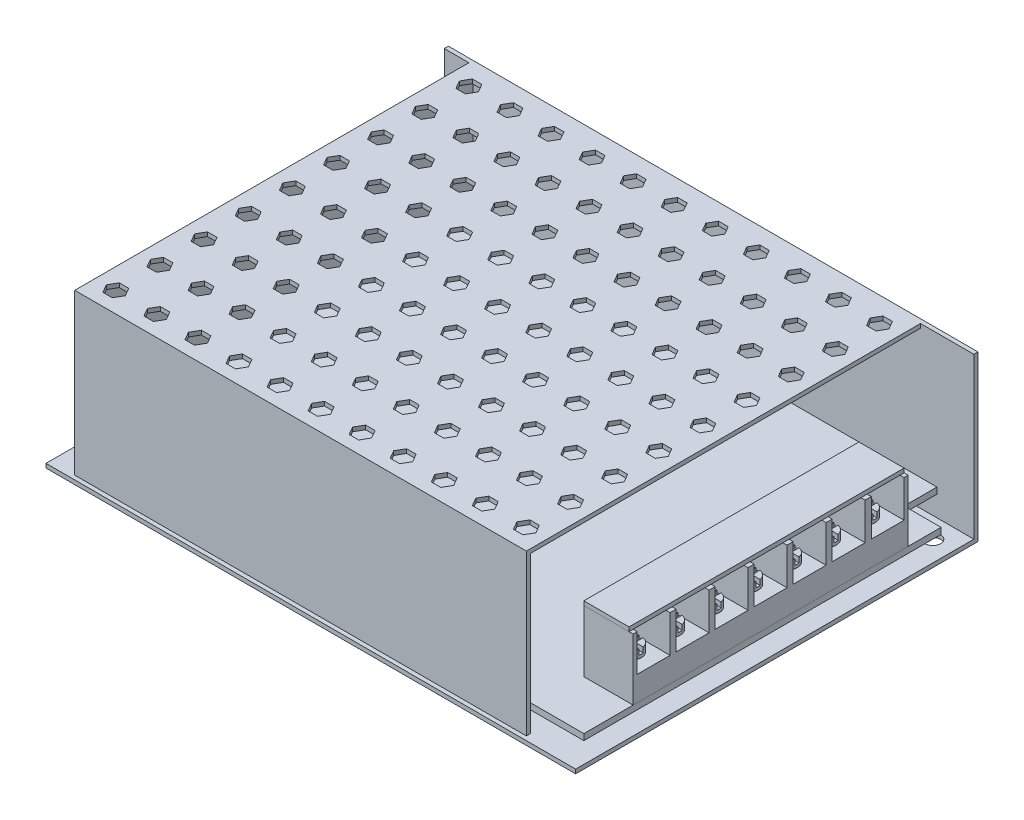
from build123d import *

# Parameters (mm, degrees)
SKETCH1_W           = 129
SKETCH1_H           = 98
BOSS_EXTRUDE1_DEPTH = 1
BOSS_EXTRUDE2_DEPTH = 39
SKETCH4_W           = 110
SKETCH4_H           = 1
BOSS_EXTRUDE3_DEPTH = 95
CUT_EXTRUDE1_DEPTH  = 1
BOSS_EXTRUDE4_DEPTH = 1.5
SKETCH8_W           = 12
SKETCH8_H           = 67
BOSS_EXTRUDE5_DEPTH = 15
SKETCH9_W           = 11
SKETCH9_H           = 8
CUT_EXTRUDE2_DEPTH  = 9
SKETCH10_R          = 2.5
BOSS_EXTRUDE6_DEPTH = 2
CUT_EXTRUDE3_DEPTH  = 1.25
LPATTERN4_COUNT     = 7
LPATTERN4_PITCH     = 9.493925628
LPATTERN4_2_COUNT   = 7
LPATTERN4_2_PITCH   = 9.493925628
SKETCH12_W          = 11
SKETCH12_H          = 67
BOSS_EXTRUDE7_DEPTH = 1
SKETCH13_R          = 1.9
CUT_EXTRUDE4_DEPTH  = 90.901334807


with BuildPart() as part:
    # Sketch1 → Boss-Extrude1 (new body)
    with BuildSketch(Plane(origin=(0, 0, 0), x_dir=(1, 0, 0), z_dir=(0, 1, 0))):
        Rectangle(SKETCH1_W, SKETCH1_H)
    extrude(amount=BOSS_EXTRUDE1_DEPTH)

    # Sketch2 → Boss-Extrude2 (add)
    with BuildSketch(Plane(origin=(0, 1, 0), x_dir=(1, 0, 0), z_dir=(0, 1, 0))):
        Polygon((-64.5, 49), (64.5, 49), (64.5, 48), (-57.5, 48), (-57.5, -47), (51.5, -47), (51.5, -48), (-58.5, -48), (-58.5, -47), (-58.5, 48), (-64.5, 48), align=None)
    extrude(amount=BOSS_EXTRUDE2_DEPTH)

    # Sketch4 → Boss-Extrude3 (add)
    with BuildSketch(Plane(origin=(0, 0, 47), x_dir=(-1, 0, 0), z_dir=(0, 0, -1))):
        with Locations((3.5, 39.5)):
            Rectangle(SKETCH4_W, SKETCH4_H)
    extrude(amount=BOSS_EXTRUDE3_DEPTH)

    # Sketch5 → Cut-Extrude1 (cut)
    with BuildSketch(Plane(origin=(0, 40, 0), x_dir=(1, 0, 0), z_dir=(0, 1, 0))):
        Polygon((-51.190598923, 43), (-52.345299462, 45), (-54.654700538, 45), (-55.809401077, 43), (-54.654700538, 41), (-52.345299462, 41), align=None)
        Polygon((-41.190598923, 43), (-42.345299462, 45), (-44.654700538, 45), (-45.809401077, 43), (-44.654700538, 41), (-42.345299462, 41), align=None)
        Polygon((-31.190598923, 43), (-32.345299462, 45), (-34.654700538, 45), (-35.809401077, 43), (-34.654700538, 41), (-32.345299462, 41), align=None)
        Polygon((-21.190598923, 43), (-22.345299462, 45), (-24.654700538, 45), (-25.809401077, 43), (-24.654700538, 41), (-22.345299462, 41), align=None)
        Polygon((-11.190598923, 43), (-12.345299462, 45), (-14.654700538, 45), (-15.809401077, 43), (-14.654700538, 41), (-12.345299462, 41), align=None)
        Polygon((-1.190598923, 43), (-2.345299462, 45), (-4.654700538, 45), (-5.809401077, 43), (-4.654700538, 41), (-2.345299462, 41), align=None)
        Polygon((8.809401077, 43), (7.654700538, 45), (5.345299462, 45), (4.190598923, 43), (5.345299462, 41), (7.654700538, 41), align=None)
        Polygon((18.809401077, 43), (17.654700538, 45), (15.345299462, 45), (14.190598923, 43), (15.345299462, 41), (17.654700538, 41), align=None)
        Polygon((28.809401077, 43), (27.654700538, 45), (25.345299462, 45), (24.190598923, 43), (25.345299462, 41), (27.654700538, 41), align=None)
        Polygon((38.809401077, 43), (37.654700538, 45), (35.345299462, 45), (34.190598923, 43), (35.345299462, 41), (37.654700538, 41), align=None)
        Polygon((48.809401077, 43), (47.654700538, 45), (45.345299462, 45), (44.190598923, 43), (45.345299462, 41), (47.654700538, 41), align=None)
        Polygon((-41.190598923, 32.25), (-42.345299462, 34.25), (-44.654700538, 34.25), (-45.809401077, 32.25), (-44.654700538, 30.25), (-42.345299462, 30.25), align=None)
        Polygon((-31.190598923, 32.25), (-32.345299462, 34.25), (-34.654700538, 34.25), (-35.809401077, 32.25), (-34.654700538, 30.25), (-32.345299462, 30.25), align=None)
        Polygon((-21.190598923, 32.25), (-22.345299462, 34.25), (-24.654700538, 34.25), (-25.809401077, 32.25), (-24.654700538, 30.25), (-22.345299462, 30.25), align=None)
        Polygon((-11.190598923, 32.25), (-12.345299462, 34.25), (-14.654700538, 34.25), (-15.809401077, 32.25), (-14.654700538, 30.25), (-12.345299462, 30.25), align=None)
        Polygon((-1.190598923, 32.25), (-2.345299462, 34.25), (-4.654700538, 34.25), (-5.809401077, 32.25), (-4.654700538, 30.25), (-2.345299462, 30.25), align=None)
        Polygon((8.809401077, 32.25), (7.654700538, 34.25), (5.345299462, 34.25), (4.190598923, 32.25), (5.345299462, 30.25), (7.654700538, 30.25), align=None)
        Polygon((18.809401077, 32.25), (17.654700538, 34.25), (15.345299462, 34.25), (14.190598923, 32.25), (15.345299462, 30.25), (17.654700538, 30.25), align=None)
        Polygon((28.809401077, 32.25), (27.654700538, 34.25), (25.345299462, 34.25), (24.190598923, 32.25), (25.345299462, 30.25), (27.654700538, 30.25), align=None)
        Polygon((38.809401077, 32.25), (37.654700538, 34.25), (35.345299462, 34.25), (34.190598923, 32.25), (35.345299462, 30.25), (37.654700538, 30.25), align=None)
        Polygon((48.809401077, 32.25), (47.654700538, 34.25), (45.345299462, 34.25), (44.190598923, 32.25), (45.345299462, 30.25), (47.654700538, 30.25), align=None)
        Polygon((-41.190598923, 21.5), (-42.345299462, 23.5), (-44.654700538, 23.5), (-45.809401077, 21.5), (-44.654700538, 19.5), (-42.345299462, 19.5), align=None)
        Polygon((-31.190598923, 21.5), (-32.345299462, 23.5), (-34.654700538, 23.5), (-35.809401077, 21.5), (-34.654700538, 19.5), (-32.345299462, 19.5), align=None)
        Polygon((-21.190598923, 21.5), (-22.345299462, 23.5), (-24.654700538, 23.5), (-25.809401077, 21.5), (-24.654700538, 19.5), (-22.345299462, 19.5), align=None)
        Polygon((-11.190598923, 21.5), (-12.345299462, 23.5), (-14.654700538, 23.5), (-15.809401077, 21.5), (-14.654700538, 19.5), (-12.345299462, 19.5), align=None)
        Polygon((-1.190598923, 21.5), (-2.345299462, 23.5), (-4.654700538, 23.5), (-5.809401077, 21.5), (-4.654700538, 19.5), (-2.345299462, 19.5), align=None)
        Polygon((8.809401077, 21.5), (7.654700538, 23.5), (5.345299462, 23.5), (4.190598923, 21.5), (5.345299462, 19.5), (7.654700538, 19.5), align=None)
        Polygon((18.809401077, 21.5), (17.654700538, 23.5), (15.345299462, 23.5), (14.190598923, 21.5), (15.345299462, 19.5), (17.654700538, 19.5), align=None)
        Polygon((28.809401077, 21.5), (27.654700538, 23.5), (25.345299462, 23.5), (24.190598923, 21.5), (25.345299462, 19.5), (27.654700538, 19.5), align=None)
        Polygon((38.809401077, 21.5), (37.654700538, 23.5), (35.345299462, 23.5), (34.190598923, 21.5), (35.345299462, 19.5), (37.654700538, 19.5), align=None)
        Polygon((48.809401077, 21.5), (47.654700538, 23.5), (45.345299462, 23.5), (44.190598923, 21.5), (45.345299462, 19.5), (47.654700538, 19.5), align=None)
        Polygon((-41.190598923, 10.75), (-42.345299462, 12.75), (-44.654700538, 12.75), (-45.809401077, 10.75), (-44.654700538, 8.75), (-42.345299462, 8.75), align=None)
        Polygon((-31.190598923, 10.75), (-32.345299462, 12.75), (-34.654700538, 12.75), (-35.809401077, 10.75), (-34.654700538, 8.75), (-32.345299462, 8.75), align=None)
        Polygon((-21.190598923, 10.75), (-22.345299462, 12.75), (-24.654700538, 12.75), (-25.809401077, 10.75), (-24.654700538, 8.75), (-22.345299462, 8.75), align=None)
        Polygon((-11.190598923, 10.75), (-12.345299462, 12.75), (-14.654700538, 12.75), (-15.809401077, 10.75), (-14.654700538, 8.75), (-12.345299462, 8.75), align=None)
        Polygon((-1.190598923, 10.75), (-2.345299462, 12.75), (-4.654700538, 12.75), (-5.809401077, 10.75), (-4.654700538, 8.75), (-2.345299462, 8.75), align=None)
        Polygon((8.809401077, 10.75), (7.654700538, 12.75), (5.345299462, 12.75), (4.190598923, 10.75), (5.345299462, 8.75), (7.654700538, 8.75), align=None)
        Polygon((18.809401077, 10.75), (17.654700538, 12.75), (15.345299462, 12.75), (14.190598923, 10.75), (15.345299462, 8.75), (17.654700538, 8.75), align=None)
        Polygon((28.809401077, 10.75), (27.654700538, 12.75), (25.345299462, 12.75), (24.190598923, 10.75), (25.345299462, 8.75), (27.654700538, 8.75), align=None)
        Polygon((38.809401077, 10.75), (37.654700538, 12.75), (35.345299462, 12.75), (34.190598923, 10.75), (35.345299462, 8.75), (37.654700538, 8.75), align=None)
        Polygon((48.809401077, 10.75), (47.654700538, 12.75), (45.345299462, 12.75), (44.190598923, 10.75), (45.345299462, 8.75), (47.654700538, 8.75), align=None)
        Polygon((-41.190598923, 0), (-42.345299462, 2), (-44.654700538, 2), (-45.809401077, 0), (-44.654700538, -2), (-42.345299462, -2), align=None)
        Polygon((-31.190598923, 0), (-32.345299462, 2), (-34.654700538, 2), (-35.809401077, 0), (-34.654700538, -2), (-32.345299462, -2), align=None)
        Polygon((-21.190598923, 0), (-22.345299462, 2), (-24.654700538, 2), (-25.809401077, 0), (-24.654700538, -2), (-22.345299462, -2), align=None)
        Polygon((-11.190598923, 0), (-12.345299462, 2), (-14.654700538, 2), (-15.809401077, 0), (-14.654700538, -2), (-12.345299462, -2), align=None)
        Polygon((-1.190598923, 0), (-2.345299462, 2), (-4.654700538, 2), (-5.809401077, 0), (-4.654700538, -2), (-2.345299462, -2), align=None)
        Polygon((8.809401077, 0), (7.654700538, 2), (5.345299462, 2), (4.190598923, 0), (5.345299462, -2), (7.654700538, -2), align=None)
        Polygon((18.809401077, 0), (17.654700538, 2), (15.345299462, 2), (14.190598923, 0), (15.345299462, -2), (17.654700538, -2), align=None)
        Polygon((28.809401077, 0), (27.654700538, 2), (25.345299462, 2), (24.190598923, 0), (25.345299462, -2), (27.654700538, -2), align=None)
        Polygon((38.809401077, 0), (37.654700538, 2), (35.345299462, 2), (34.190598923, 0), (35.345299462, -2), (37.654700538, -2), align=None)
        Polygon((48.809401077, 0), (47.654700538, 2), (45.345299462, 2), (44.190598923, 0), (45.345299462, -2), (47.654700538, -2), align=None)
        Polygon((-41.190598923, -10.75), (-42.345299462, -8.75), (-44.654700538, -8.75), (-45.809401077, -10.75), (-44.654700538, -12.75), (-42.345299462, -12.75), align=None)
        Polygon((-31.190598923, -10.75), (-32.345299462, -8.75), (-34.654700538, -8.75), (-35.809401077, -10.75), (-34.654700538, -12.75), (-32.345299462, -12.75), align=None)
        Polygon((-21.190598923, -10.75), (-22.345299462, -8.75), (-24.654700538, -8.75), (-25.809401077, -10.75), (-24.654700538, -12.75), (-22.345299462, -12.75), align=None)
        Polygon((-11.190598923, -10.75), (-12.345299462, -8.75), (-14.654700538, -8.75), (-15.809401077, -10.75), (-14.654700538, -12.75), (-12.345299462, -12.75), align=None)
        Polygon((-1.190598923, -10.75), (-2.345299462, -8.75), (-4.654700538, -8.75), (-5.809401077, -10.75), (-4.654700538, -12.75), (-2.345299462, -12.75), align=None)
        Polygon((8.809401077, -10.75), (7.654700538, -8.75), (5.345299462, -8.75), (4.190598923, -10.75), (5.345299462, -12.75), (7.654700538, -12.75), align=None)
        Polygon((18.809401077, -10.75), (17.654700538, -8.75), (15.345299462, -8.75), (14.190598923, -10.75), (15.345299462, -12.75), (17.654700538, -12.75), align=None)
        Polygon((28.809401077, -10.75), (27.654700538, -8.75), (25.345299462, -8.75), (24.190598923, -10.75), (25.345299462, -12.75), (27.654700538, -12.75), align=None)
        Polygon((38.809401077, -10.75), (37.654700538, -8.75), (35.345299462, -8.75), (34.190598923, -10.75), (35.345299462, -12.75), (37.654700538, -12.75), align=None)
        Polygon((48.809401077, -10.75), (47.654700538, -8.75), (45.345299462, -8.75), (44.190598923, -10.75), (45.345299462, -12.75), (47.654700538, -12.75), align=None)
        Polygon((-41.190598923, -21.5), (-42.345299462, -19.5), (-44.654700538, -19.5), (-45.809401077, -21.5), (-44.654700538, -23.5), (-42.345299462, -23.5), align=None)
        Polygon((-31.190598923, -21.5), (-32.345299462, -19.5), (-34.654700538, -19.5), (-35.809401077, -21.5), (-34.654700538, -23.5), (-32.345299462, -23.5), align=None)
        Polygon((-21.190598923, -21.5), (-22.345299462, -19.5), (-24.654700538, -19.5), (-25.809401077, -21.5), (-24.654700538, -23.5), (-22.345299462, -23.5), align=None)
        Polygon((-11.190598923, -21.5), (-12.345299462, -19.5), (-14.654700538, -19.5), (-15.809401077, -21.5), (-14.654700538, -23.5), (-12.345299462, -23.5), align=None)
        Polygon((-1.190598923, -21.5), (-2.345299462, -19.5), (-4.654700538, -19.5), (-5.809401077, -21.5), (-4.654700538, -23.5), (-2.345299462, -23.5), align=None)
        Polygon((8.809401077, -21.5), (7.654700538, -19.5), (5.345299462, -19.5), (4.190598923, -21.5), (5.345299462, -23.5), (7.654700538, -23.5), align=None)
        Polygon((18.809401077, -21.5), (17.654700538, -19.5), (15.345299462, -19.5), (14.190598923, -21.5), (15.345299462, -23.5), (17.654700538, -23.5), align=None)
        Polygon((28.809401077, -21.5), (27.654700538, -19.5), (25.345299462, -19.5), (24.190598923, -21.5), (25.345299462, -23.5), (27.654700538, -23.5), align=None)
        Polygon((38.809401077, -21.5), (37.654700538, -19.5), (35.345299462, -19.5), (34.190598923, -21.5), (35.345299462, -23.5), (37.654700538, -23.5), align=None)
        Polygon((48.809401077, -21.5), (47.654700538, -19.5), (45.345299462, -19.5), (44.190598923, -21.5), (45.345299462, -23.5), (47.654700538, -23.5), align=None)
        Polygon((-41.190598923, -32.25), (-42.345299462, -30.25), (-44.654700538, -30.25), (-45.809401077, -32.25), (-44.654700538, -34.25), (-42.345299462, -34.25), align=None)
        Polygon((-31.190598923, -32.25), (-32.345299462, -30.25), (-34.654700538, -30.25), (-35.809401077, -32.25), (-34.654700538, -34.25), (-32.345299462, -34.25), align=None)
        Polygon((-21.190598923, -32.25), (-22.345299462, -30.25), (-24.654700538, -30.25), (-25.809401077, -32.25), (-24.654700538, -34.25), (-22.345299462, -34.25), align=None)
        Polygon((-11.190598923, -32.25), (-12.345299462, -30.25), (-14.654700538, -30.25), (-15.809401077, -32.25), (-14.654700538, -34.25), (-12.345299462, -34.25), align=None)
        Polygon((-1.190598923, -32.25), (-2.345299462, -30.25), (-4.654700538, -30.25), (-5.809401077, -32.25), (-4.654700538, -34.25), (-2.345299462, -34.25), align=None)
        Polygon((8.809401077, -32.25), (7.654700538, -30.25), (5.345299462, -30.25), (4.190598923, -32.25), (5.345299462, -34.25), (7.654700538, -34.25), align=None)
        Polygon((18.809401077, -32.25), (17.654700538, -30.25), (15.345299462, -30.25), (14.190598923, -32.25), (15.345299462, -34.25), (17.654700538, -34.25), align=None)
        Polygon((28.809401077, -32.25), (27.654700538, -30.25), (25.345299462, -30.25), (24.190598923, -32.25), (25.345299462, -34.25), (27.654700538, -34.25), align=None)
        Polygon((38.809401077, -32.25), (37.654700538, -30.25), (35.345299462, -30.25), (34.190598923, -32.25), (35.345299462, -34.25), (37.654700538, -34.25), align=None)
        Polygon((48.809401077, -32.25), (47.654700538, -30.25), (45.345299462, -30.25), (44.190598923, -32.25), (45.345299462, -34.25), (47.654700538, -34.25), align=None)
        Polygon((-41.190598923, -43), (-42.345299462, -41), (-44.654700538, -41), (-45.809401077, -43), (-44.654700538, -45), (-42.345299462, -45), align=None)
        Polygon((-31.190598923, -43), (-32.345299462, -41), (-34.654700538, -41), (-35.809401077, -43), (-34.654700538, -45), (-32.345299462, -45), align=None)
        Polygon((-21.190598923, -43), (-22.345299462, -41), (-24.654700538, -41), (-25.809401077, -43), (-24.654700538, -45), (-22.345299462, -45), align=None)
        Polygon((-11.190598923, -43), (-12.345299462, -41), (-14.654700538, -41), (-15.809401077, -43), (-14.654700538, -45), (-12.345299462, -45), align=None)
        Polygon((-1.190598923, -43), (-2.345299462, -41), (-4.654700538, -41), (-5.809401077, -43), (-4.654700538, -45), (-2.345299462, -45), align=None)
        Polygon((8.809401077, -43), (7.654700538, -41), (5.345299462, -41), (4.190598923, -43), (5.345299462, -45), (7.654700538, -45), align=None)
        Polygon((18.809401077, -43), (17.654700538, -41), (15.345299462, -41), (14.190598923, -43), (15.345299462, -45), (17.654700538, -45), align=None)
        Polygon((28.809401077, -43), (27.654700538, -41), (25.345299462, -41), (24.190598923, -43), (25.345299462, -45), (27.654700538, -45), align=None)
        Polygon((38.809401077, -43), (37.654700538, -41), (35.345299462, -41), (34.190598923, -43), (35.345299462, -45), (37.654700538, -45), align=None)
        Polygon((48.809401077, -43), (47.654700538, -41), (45.345299462, -41), (44.190598923, -43), (45.345299462, -45), (47.654700538, -45), align=None)
        Polygon((-51.190598923, 32.25), (-52.345299462, 34.25), (-54.654700538, 34.25), (-55.809401077, 32.25), (-54.654700538, 30.25), (-52.345299462, 30.25), align=None)
        Polygon((-51.190598923, 21.5), (-52.345299462, 23.5), (-54.654700538, 23.5), (-55.809401077, 21.5), (-54.654700538, 19.5), (-52.345299462, 19.5), align=None)
        Polygon((-51.190598923, 10.75), (-52.345299462, 12.75), (-54.654700538, 12.75), (-55.809401077, 10.75), (-54.654700538, 8.75), (-52.345299462, 8.75), align=None)
        Polygon((-51.190598923, 0), (-52.345299462, 2), (-54.654700538, 2), (-55.809401077, 0), (-54.654700538, -2), (-52.345299462, -2), align=None)
        Polygon((-51.190598923, -10.75), (-52.345299462, -8.75), (-54.654700538, -8.75), (-55.809401077, -10.75), (-54.654700538, -12.75), (-52.345299462, -12.75), align=None)
        Polygon((-51.190598923, -21.5), (-52.345299462, -19.5), (-54.654700538, -19.5), (-55.809401077, -21.5), (-54.654700538, -23.5), (-52.345299462, -23.5), align=None)
        Polygon((-51.190598923, -32.25), (-52.345299462, -30.25), (-54.654700538, -30.25), (-55.809401077, -32.25), (-54.654700538, -34.25), (-52.345299462, -34.25), align=None)
        Polygon((-51.190598923, -43), (-52.345299462, -41), (-54.654700538, -41), (-55.809401077, -43), (-54.654700538, -45), (-52.345299462, -45), align=None)
    extrude(amount=-CUT_EXTRUDE1_DEPTH, mode=Mode.SUBTRACT)

    # Sketch13 → Cut-Extrude4 (cut, through all)
    with BuildSketch(Plane(origin=(0, 1, 0), x_dir=(1, 0, 0), z_dir=(0, 1, 0))):
        with Locations(Location((59.5, 43, 0), (0, 0, 270))):
            Circle(SKETCH13_R)
    extrude(amount=-CUT_EXTRUDE4_DEPTH, mode=Mode.SUBTRACT)


with BuildPart() as body_2:
    # Sketch7 → Boss-Extrude4 (new body)
    with BuildSketch(Plane(origin=(0, 6, 0), x_dir=(1, 0, 0), z_dir=(0, 1, 0))):
        Polygon((55.5, 48), (55.5, 40), (64.5, 40), (64.5, -47), (-57.5, -47), (-57.5, 48), align=None)
    extrude(amount=BOSS_EXTRUDE4_DEPTH)


with BuildPart() as body_3:
    # Sketch8 → Boss-Extrude5 (new body)
    with BuildSketch(Plane(origin=(0, 7.5, 0), x_dir=(1, 0, 0), z_dir=(0, 1, 0))):
        with Locations((58.5, -1.5)):
            Rectangle(SKETCH8_W, SKETCH8_H)
    extrude(amount=BOSS_EXTRUDE5_DEPTH)

    # Sketch9 → Cut-Extrude2 (cut)
    with BuildSketch(Plane(origin=(0, 22.5, 0), x_dir=(1, 0, 0), z_dir=(0, 1, 0))):
        with Locations((59, -30)):
            Rectangle(SKETCH9_W, SKETCH9_H)
        with Locations((59, -20.5)):
            Rectangle(SKETCH9_W, SKETCH9_H)
        with Locations((59, -11)):
            Rectangle(SKETCH9_W, SKETCH9_H)
        with Locations((59, -1.5)):
            Rectangle(SKETCH9_W, SKETCH9_H)
        with Locations((59, 8)):
            Rectangle(SKETCH9_W, SKETCH9_H)
        with Locations((59, 17.5)):
            Rectangle(SKETCH9_W, SKETCH9_H)
        with Locations((59, 27)):
            Rectangle(SKETCH9_W, SKETCH9_H)
    extrude(amount=-CUT_EXTRUDE2_DEPTH, mode=Mode.SUBTRACT)


with BuildPart() as body_4:
    # Sketch10 → Boss-Extrude6 (new body)
    with BuildSketch(Plane(origin=(0, 13.5, 0), x_dir=(1, 0, 0), z_dir=(0, 1, 0))):
        with Locations(Location((59, -30, 0), (0, 0, 270))):
            Circle(SKETCH10_R)
    boss_extrude6 = extrude(amount=BOSS_EXTRUDE6_DEPTH)

    # Sketch11 → Cut-Extrude3 (cut)
    with BuildSketch(Plane(origin=(0, 15.5, 0), x_dir=(1, 0, 0), z_dir=(0, 1, 0))):
        Polygon((62.497624325, -29.5), (62.497624325, -30.5), (59.5, -30.5), (59.5, -33.166665013), (58.5, -33.166665013), (58.5, -30.5), (55.577516505, -30.5), (55.577516505, -29.5), (58.5, -29.5), (58.5, -26.693775045), (59.5, -26.693775045), (59.5, -29.5), align=None)
    cut_extrude3 = extrude(amount=-CUT_EXTRUDE3_DEPTH, mode=Mode.SUBTRACT)


with BuildPart() as lpattern4_1:
    # LPattern4: pattern copy
    add(boss_extrude6.moved(Location(Vector(0, 0, -1) * (1 * LPATTERN4_PITCH))))


with BuildPart() as lpattern4_2:
    # LPattern4: pattern copy
    add(boss_extrude6.moved(Location(Vector(0, 0, -1) * (2 * LPATTERN4_PITCH))))


with BuildPart() as lpattern4_3:
    # LPattern4: pattern copy
    add(boss_extrude6.moved(Location(Vector(0, 0, -1) * (3 * LPATTERN4_PITCH))))


with BuildPart() as lpattern4_4:
    # LPattern4: pattern copy
    add(boss_extrude6.moved(Location(Vector(0, 0, -1) * (4 * LPATTERN4_PITCH))))


with BuildPart() as lpattern4_5:
    # LPattern4: pattern copy
    add(boss_extrude6.moved(Location(Vector(0, 0, -1) * (5 * LPATTERN4_PITCH))))


with BuildPart() as lpattern4_6:
    # LPattern4: pattern copy
    add(boss_extrude6.moved(Location(Vector(0, 0, -1) * (6 * LPATTERN4_PITCH))))


with BuildPart() as lpattern4_2_tool:
    # LPattern4 2: Cut-Extrude3 ×7
    with Locations(*[(0, 0, -i * LPATTERN4_2_PITCH) for i in range(1, LPATTERN4_2_COUNT)]):
        add(cut_extrude3)


with BuildPart() as lpattern4_1_1:
    add(lpattern4_1.part)

    # LPattern4 2: cut by lpattern4_2_tool
    add(lpattern4_2_tool.part, mode=Mode.SUBTRACT)


with BuildPart() as lpattern4_2_1:
    add(lpattern4_2.part)

    # LPattern4 2: cut by lpattern4_2_tool
    add(lpattern4_2_tool.part, mode=Mode.SUBTRACT)


with BuildPart() as lpattern4_3_1:
    add(lpattern4_3.part)

    # LPattern4 2: cut by lpattern4_2_tool
    add(lpattern4_2_tool.part, mode=Mode.SUBTRACT)


with BuildPart() as lpattern4_4_1:
    add(lpattern4_4.part)

    # LPattern4 2: cut by lpattern4_2_tool
    add(lpattern4_2_tool.part, mode=Mode.SUBTRACT)


with BuildPart() as lpattern4_5_1:
    add(lpattern4_5.part)

    # LPattern4 2: cut by lpattern4_2_tool
    add(lpattern4_2_tool.part, mode=Mode.SUBTRACT)


with BuildPart() as lpattern4_6_1:
    add(lpattern4_6.part)

    # LPattern4 2: cut by lpattern4_2_tool
    add(lpattern4_2_tool.part, mode=Mode.SUBTRACT)


with BuildPart() as body_11:
    # Sketch12 → Boss-Extrude7 (new body)
    with BuildSketch(Plane(origin=(0, 22.5, 0), x_dir=(1, 0, 0), z_dir=(0, 1, 0))):
        with Locations((58, -1.5)):
            Rectangle(SKETCH12_W, SKETCH12_H)
    extrude(amount=BOSS_EXTRUDE7_DEPTH)


solid = Compound([part.part, body_2.part, body_3.part, body_4.part, lpattern4_1_1.part, lpattern4_2_1.part, lpattern4_3_1.part, lpattern4_4_1.part, lpattern4_5_1.part, lpattern4_6_1.part, body_11.part])
